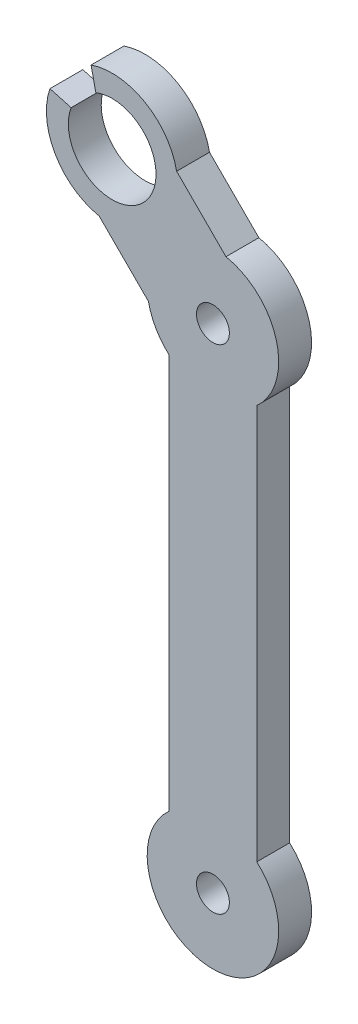
from build123d import *

# Parameters (mm, degrees)
ESQUISSE1_R        = 6
ESQUISSE1_R_2      = 1.5
BOSS_EXTRU_1_DEPTH = 3


with BuildPart() as part:
    # Esquisse1 → Boss.-Extru.1 (new body)
    with BuildSketch(Plane.XY):
        with Locations((0, 45)):
            Circle(ESQUISSE1_R)
        with Locations((0, 45)):
            Circle(ESQUISSE1_R_2, mode=Mode.SUBTRACT)
        with BuildLine():
            Line((4, 4.472135955), (4, 40.527864045))
            ThreePointArc((4, 40.527864045), (0, 39), (-4, 40.527864045))
            Line((-4, 40.527864045), (-4, 4.472135955))
            ThreePointArc((-4, 4.472135955), (0, 6), (4, 4.472135955))
        make_face()
        Circle(ESQUISSE1_R)
        Circle(ESQUISSE1_R_2, mode=Mode.SUBTRACT)
        with BuildLine():
            Line((-10.382714181, 48.31164637), (-5.880741786, 43.809673974))
            ThreePointArc((-5.880741786, 43.809673974), (-4.242640687, 49.242640687), (1.190326026, 50.880741786))
            Line((1.190326026, 50.880741786), (-3.31164637, 55.382714181))
            ThreePointArc((-3.31164637, 55.382714181), (-4.949747468, 49.949747468), (-10.382714181, 48.31164637))
        make_face()
        with BuildLine():
            ThreePointArc((-12.939033763, 55.593333084), (-6.330461198, 51.397862419), (-10.682211275, 57.904587917))
            Line((-10.682211275, 57.904587917), (-11.115778297, 59.875747229))
            ThreePointArc((-11.115778297, 59.875747229), (-4.955475233, 49.944027426), (-14.870536711, 56.131106542))
            Line((-14.870536711, 56.131106542), (-12.939033763, 55.593333084))
        make_face()
    extrude(amount=BOSS_EXTRU_1_DEPTH)


solid = part.part
